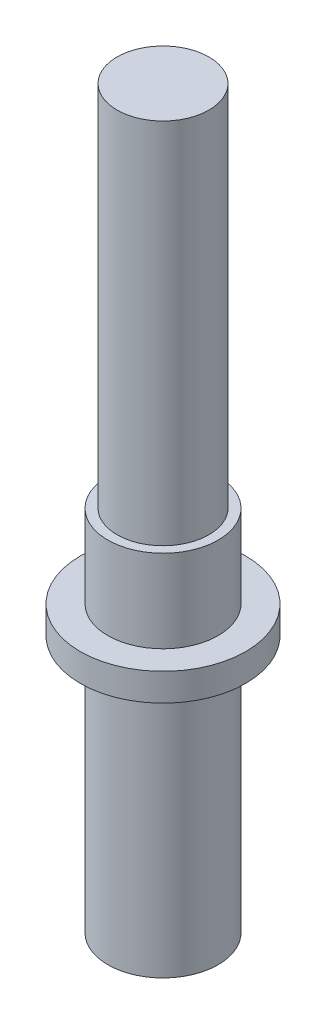
from build123d import *


with BuildPart() as part:
    # Sketch1 → Revolve1 (revolve)
    with BuildSketch(Plane.XY):
        Polygon((0, 0), (3, 0), (3, 14), (4.5, 14), (4.5, 15.5), (3, 15.5), (3, 20), (2.5, 20), (2.5, 40), (0, 40), align=None)
    revolve(axis=Axis((0, 0, 0), (0, 1, 0)))


solid = part.part
